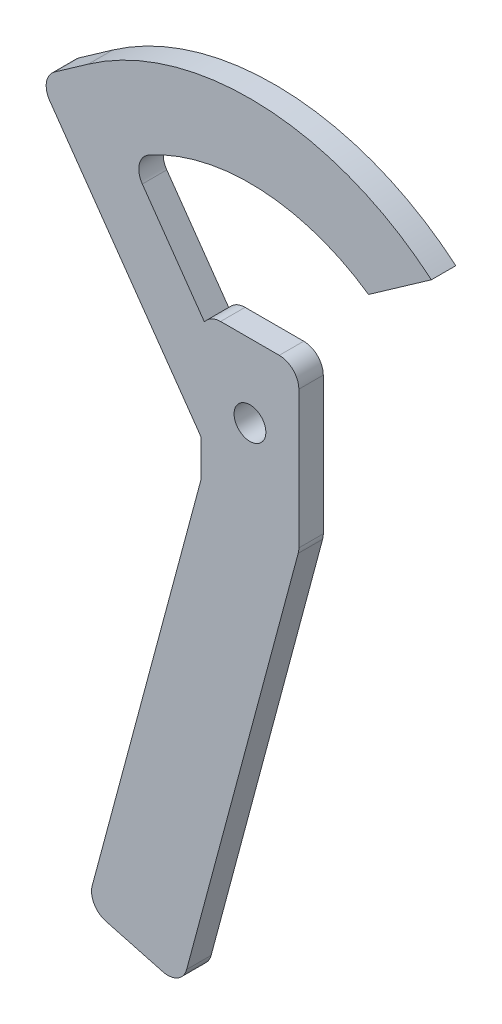
from build123d import *

# Parameters (mm, degrees)
MODEL_R             = 3.25
MODEL_R_2           = 2.075
BOSS_EXTRUDE1_DEPTH = 5


with BuildPart() as part:
    # Model → Boss-Extrude1 (new body)
    with BuildSketch(Plane.XY):
        with BuildLine():
            Line((299.530455157, 221.325483104), (287.530455157, 221.325483104))
            ThreePointArc((287.530455157, 221.325483104), (284.702028033, 220.153910229), (283.530455157, 217.325483104))
            Line((283.530455157, 217.325483104), (283.530455157, 191.852093095))
            ThreePointArc((283.530455157, 191.852093095), (283.496234603, 191.329988326), (283.394158462, 190.816816914))
            Line((283.394158462, 190.816816914), (261.272017278, 108.255862044))
            ThreePointArc((261.272017278, 108.255862044), (261.671618968, 105.220585863), (264.100444403, 103.356882558))
            Line((264.100444403, 103.356882558), (275.691554319, 100.251054017))
            ThreePointArc((275.691554319, 100.251054017), (278.726830499, 100.650655707), (280.590533804, 103.079481141))
            Line((280.590533804, 103.079481141), (303.394158462, 188.183766963))
            ThreePointArc((303.394158462, 188.183766963), (303.496234603, 188.696938374), (303.530455157, 189.219043143))
            Line((303.530455157, 189.219043143), (303.530455157, 217.325483104))
            ThreePointArc((303.530455157, 217.325483104), (302.358882282, 220.153910229), (299.530455157, 221.325483104))
        make_face()
        with Locations((293.530455157, 206.325483104)):
            Circle(MODEL_R, mode=Mode.SUBTRACT)
        with Locations((293.530455157, 214.325483104)):
            Circle(MODEL_R_2, mode=Mode.SUBTRACT)
        with Locations((293.530455157, 198.325483104)):
            Circle(MODEL_R_2, mode=Mode.SUBTRACT)
        with BuildLine():
            ThreePointArc((330.635106632, 250.251498618), (296.090916254, 263.768446459), (260.481102457, 253.378541305))
            Line((260.481102457, 253.378541305), (253.558218086, 248.516012577))
            ThreePointArc((253.558218086, 248.516012577), (251.917062939, 245.931599145), (252.584047269, 242.943670949))
            Line((252.584047269, 242.943670949), (282.759543213, 199.982183026))
            Line((282.759543213, 199.982183026), (283.508108229, 198.855371857))
            Line((283.508108229, 198.855371857), (283.530455157, 198.825483104))
            Line((283.530455157, 198.825483104), (283.530455157, 217.325483104))
            ThreePointArc((283.530455157, 217.325483104), (283.70765552, 218.5028543), (284.223556624, 219.575910195))
            Line((284.223556624, 219.575910195), (271.521515193, 237.660073602))
            ThreePointArc((271.521515193, 237.660073602), (270.895698021, 240.852034508), (272.848206871, 243.453566893))
            ThreePointArc((272.848206871, 243.453566893), (295.63531403, 248.773328387), (317.784347872, 241.225321044))
            Line((317.784347872, 241.225321044), (330.635106632, 250.251498618))
        make_face()
        with Locations((293.530455157, 198.325483104)):
            Circle(MODEL_R_2)
        with Locations((293.530455157, 214.325483104)):
            Circle(MODEL_R_2)
    extrude(amount=BOSS_EXTRUDE1_DEPTH)


solid = part.part
